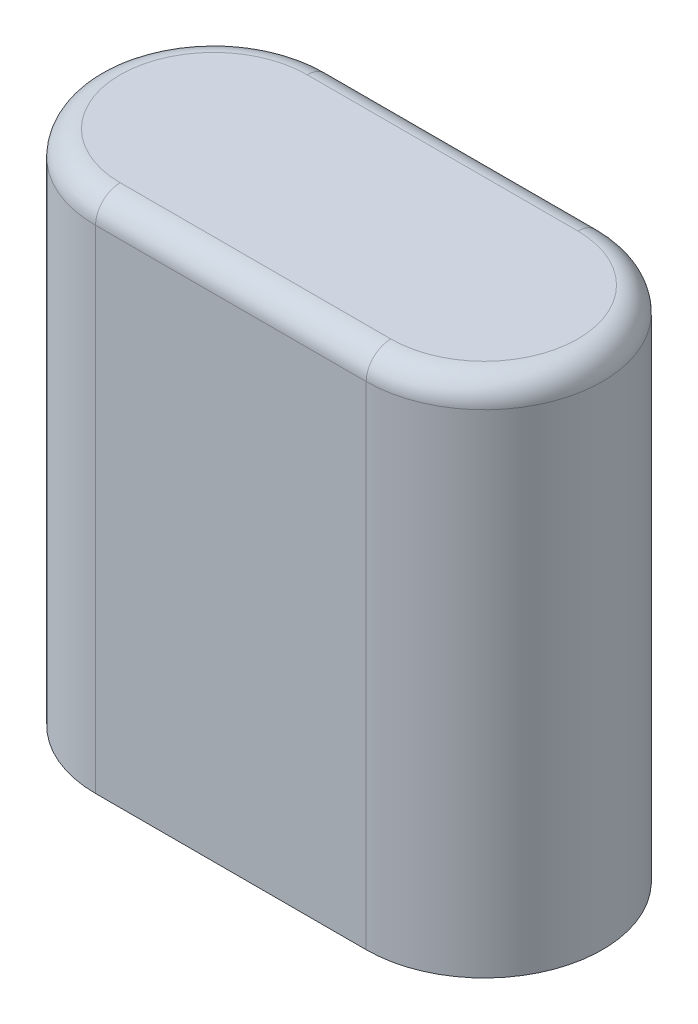
from build123d import *

# Parameters (mm, degrees)
BOSS_EXTRUDE1_DEPTH = 13.335
FILLET1_R           = 0.635
SKETCH2_R           = 1.778
CUT_EXTRUDE3_DEPTH  = 6.985


with BuildPart() as part:
    # Sketch1 → Boss-Extrude1 (new body)
    with BuildSketch(Plane(origin=(0, 0, 0), x_dir=(1, 0, 0), z_dir=(0, 1, 0))):
        with BuildLine():
            Line((-3.4925, 3.048), (3.4925, 3.048))
            ThreePointArc((3.4925, 3.048), (6.5405, 0), (3.4925, -3.048))
            Line((3.4925, -3.048), (-3.4925, -3.048))
            ThreePointArc((-3.4925, -3.048), (-6.5405, 0), (-3.4925, 3.048))
        make_face()
    extrude(amount=BOSS_EXTRUDE1_DEPTH)

    # Fillet1
    fillet1_edges = [part.edges().sort_by_distance(p)[0] for p in [
        (6.5405, 13.335, 0),
        (0, 13.335, -3.048),
        (-6.5405, 13.335, 0),
        (0, 13.335, 3.048),
    ]]
    fillet(fillet1_edges, radius=FILLET1_R)

    # Sketch2 → Cut-Extrude3 (cut)
    with BuildSketch(Plane.XZ):
        Circle(SKETCH2_R)
    extrude(amount=-CUT_EXTRUDE3_DEPTH, mode=Mode.SUBTRACT)


solid = part.part
